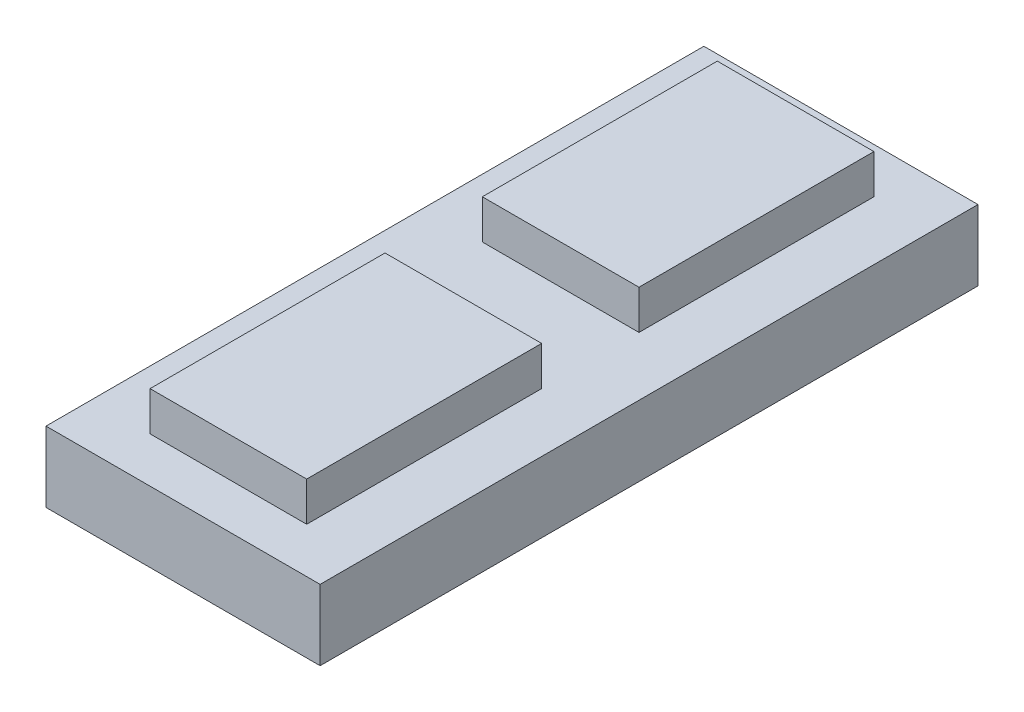
from build123d import *

# Parameters (mm, degrees)
SKETCH1_W             = 35
SKETCH1_H             = 84
BOSS_EXTRUDE1_DEPTH   = 9
SKETCH2_W             = 20
SKETCH2_H             = 30
BOSS_EXTRUDE2_DEPTH   = 5
BOSS_EXTRUDE2_2_DEPTH = 5


with BuildPart() as part:
    # Sketch1 → Boss-Extrude1 (new body)
    with BuildSketch(Plane(origin=(0, 0, 0), x_dir=(1, 0, 0), z_dir=(0, 1, 0))):
        Rectangle(SKETCH1_W, SKETCH1_H)
    extrude(amount=BOSS_EXTRUDE1_DEPTH)


with BuildPart() as body_2:
    # Sketch2 → Boss-Extrude2 (new body)
    with BuildSketch(Plane(origin=(0, 9, 0), x_dir=(1, 0, 0), z_dir=(0, 1, 0))):
        with Locations((0, 21.213224671)):
            Rectangle(SKETCH2_W, SKETCH2_H)
    extrude(amount=BOSS_EXTRUDE2_DEPTH)


with BuildPart() as body_3:
    # Sketch2 → Boss-Extrude2 2 (new body)
    with BuildSketch(Plane(origin=(0, 9, 0), x_dir=(1, 0, 0), z_dir=(0, 1, 0))):
        with Locations((0, -21.213224671)):
            Rectangle(SKETCH2_W, SKETCH2_H)
    extrude(amount=BOSS_EXTRUDE2_2_DEPTH)


solid = Compound([part.part, body_2.part, body_3.part])
